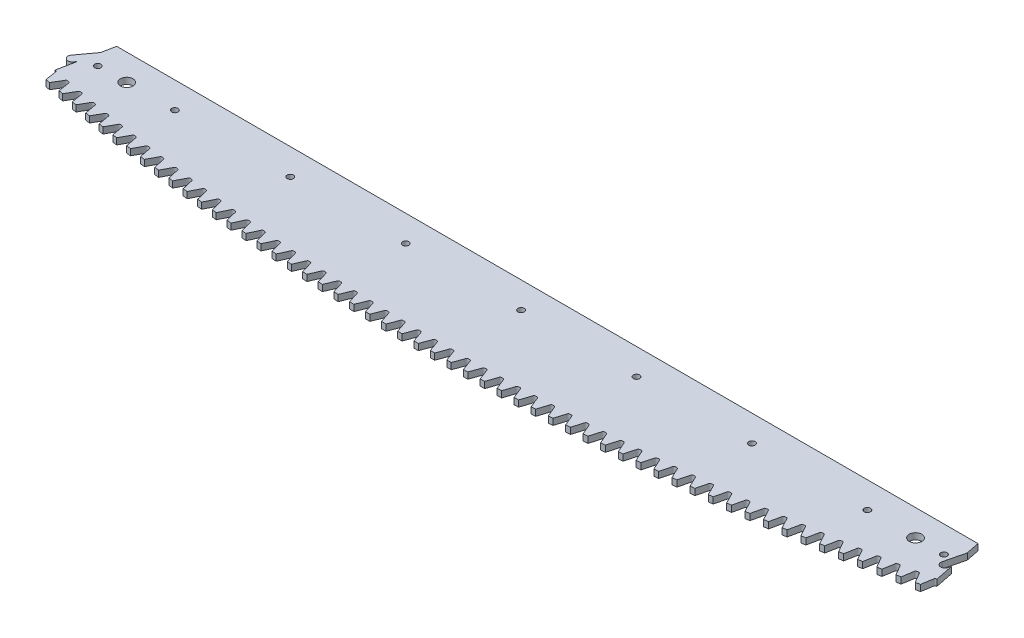
from build123d import *

# Parameters (mm, degrees)
SKETCH1_R                       = 6
SKETCH1_R_2                     = 3
BOSS_EXTRUDE1_DEPTH             = 6
CUT_EXTRUDE1_DEPTH              = 6
CIRPATTERN1_COUNT               = 28
CIRPATTERN1_ANGLE               = 11.25000009
CIRPATTERN1_THE_OTHER_WAY_COUNT = 28
CIRPATTERN1_THE_OTHER_WAY_ANGLE = 11.25000009
CUT_EXTRUDE2_DEPTH              = 6
BOSS_EXTRUDE4_DEPTH             = 6


with BuildPart() as part:
    # Sketch1 → Boss-Extrude1 (new body)
    with BuildSketch(Plane(origin=(0, 0, 0), x_dir=(1, 0, 0), z_dir=(0, 1, 0))):
        with BuildLine():
            Line((-410.440363801, -2063.423050098), (410.440363801, -2063.423050098))
            Line((410.440363801, -2063.423050098), (422.370547165, -2123.400132073))
            ThreePointArc((422.370547165, -2123.400132073), (0, -2165), (-422.370547165, -2123.400132073))
            Line((-422.370547165, -2123.400132073), (-410.440363801, -2063.423050098))
        make_face()
        with Locations((-375.934603339, -2088.423050098)):
            Circle(SKETCH1_R, mode=Mode.SUBTRACT)
        with Locations((375.934603339, -2088.423050098)):
            Circle(SKETCH1_R, mode=Mode.SUBTRACT)
        with Locations((0, -2088.423050098)):
            Circle(SKETCH1_R_2, mode=Mode.SUBTRACT)
        with Locations((110, -2088.423050098)):
            Circle(SKETCH1_R_2, mode=Mode.SUBTRACT)
        with Locations((220, -2088.423050098)):
            Circle(SKETCH1_R_2, mode=Mode.SUBTRACT)
        with Locations((330, -2088.423050098)):
            Circle(SKETCH1_R_2, mode=Mode.SUBTRACT)
        with Locations((-110, -2088.423050098)):
            Circle(SKETCH1_R_2, mode=Mode.SUBTRACT)
        with Locations((-220, -2088.423050098)):
            Circle(SKETCH1_R_2, mode=Mode.SUBTRACT)
        with Locations((-330, -2088.423050098)):
            Circle(SKETCH1_R_2, mode=Mode.SUBTRACT)
        with Locations((-403.219846097, -2088.633027037)):
            Circle(SKETCH1_R_2, mode=Mode.SUBTRACT)
        with Locations((403.219846097, -2088.633027037)):
            Circle(SKETCH1_R_2, mode=Mode.SUBTRACT)
    extrude(amount=BOSS_EXTRUDE1_DEPTH)

    # Sketch4 → Cut-Extrude1 (cut)
    with BuildSketch(Plane(origin=(0, 6, 0), x_dir=(1, 0, 0), z_dir=(0, 1, 0))):
        with BuildLine():
            ThreePointArc((5.775946522, -2164.992295238), (0, -2165), (-5.775946522, -2164.992295238))
            add(Edge.make_bspline(
                [(5.775946522, -2164.992295238), (5.674083922, -2164.720044005), (5.506178859, -2164.270486388), (5.272809935, -2163.64382032), (5.075526941, -2163.112827655), (4.879049735, -2162.582775587), (4.683376779, -2162.053665031), (4.488506537, -2161.525496899), (4.294437463, -2160.998272105), (4.101168048, -2160.471991549), (3.908696638, -2159.946656175), (3.71702211, -2159.42226675), (3.526141371, -2158.898824698), (3.336058649, -2158.376328989), (3.146750922, -2157.854787706), (2.958296557, -2157.334175032), (2.770396709, -2156.814591251), (2.584155873, -2156.29566751), (2.332577034, -2155.606535716), (2.139076064, -2155.010976967), (1.93879924, -2154.530288541), (1.81191477, -2154.337239961), (1.658884345, -2154.164884349), (1.480834065, -2154.018205562), (1.282601997, -2153.900243246), (1.06865708, -2153.814428877), (0.844082069, -2153.76051975), (0.485800933, -2153.741235255), (0, -2153.756378776), (-0.485800933, -2153.741235255), (-0.844082069, -2153.76051975), (-1.06865708, -2153.814428877), (-1.282601997, -2153.900243246), (-1.480834065, -2154.018205562), (-1.658884345, -2154.164884349), (-1.81191477, -2154.337239961), (-1.93879924, -2154.530288541), (-2.139076064, -2155.010976967), (-2.332577034, -2155.606535716), (-2.584155873, -2156.29566751), (-2.770396709, -2156.814591251), (-2.958296557, -2157.334175032), (-3.146750922, -2157.854787706), (-3.336058649, -2158.376328989), (-3.526141371, -2158.898824698), (-3.71702211, -2159.42226675), (-3.908696638, -2159.946656175), (-4.101168048, -2160.471991549), (-4.294437463, -2160.998272105), (-4.488506537, -2161.525496899), (-4.683376779, -2162.053665031), (-4.879049735, -2162.582775587), (-5.075526941, -2163.112827655), (-5.272809935, -2163.64382032), (-5.506178859, -2164.270486388), (-5.674083922, -2164.720044005), (-5.775946522, -2164.992295238)],
                knots=[0.009781048, 0.009781048, 0.009781048, 0.009781048, 0.041765812, 0.062584778, 0.083361118, 0.104094833, 0.124785921, 0.145434383, 0.166040219, 0.186603428, 0.207124012, 0.227601969, 0.2480373, 0.268430005, 0.288780084, 0.309087537, 0.329352363, 0.349574564, 0.369754138, 0.410064664, 0.418491096, 0.426917528, 0.43534396, 0.443770393, 0.452196825, 0.460623257, 0.46904969, 0.477476122, 0.5, 0.522523878, 0.53095031, 0.539376743, 0.547803175, 0.556229607, 0.56465604, 0.573082472, 0.581508904, 0.589935336, 0.630245862, 0.650425436, 0.670647637, 0.690912463, 0.711219916, 0.731569995, 0.7519627, 0.772398031, 0.792875988, 0.813396572, 0.833959781, 0.854565617, 0.875214079, 0.895905167, 0.916638882, 0.937415222, 0.958234188, 0.990218952, 0.990218952, 0.990218952, 0.990218952], degree=3))
        make_face()
    cut_extrude1 = extrude(amount=-CUT_EXTRUDE1_DEPTH, mode=Mode.SUBTRACT)

    # CirPattern1: Cut-Extrude1 ×28 about axis
    cirpattern1_axis = Axis((0, 6.3, 0), (0, -1, 0))
    for i in range(1, CIRPATTERN1_COUNT):
        add(cut_extrude1.rotate(cirpattern1_axis, i * CIRPATTERN1_ANGLE / (CIRPATTERN1_COUNT - 1)), mode=Mode.SUBTRACT)

    # CirPattern1 the other way: Cut-Extrude1 ×28 about axis
    cirpattern1_the_other_way_axis = Axis((0, 6.3, 0), (0, 1, 0))
    for i in range(1, CIRPATTERN1_THE_OTHER_WAY_COUNT):
        add(cut_extrude1.rotate(cirpattern1_the_other_way_axis, i * CIRPATTERN1_THE_OTHER_WAY_ANGLE / (CIRPATTERN1_THE_OTHER_WAY_COUNT - 1)), mode=Mode.SUBTRACT)

    # Sketch5 → Cut-Extrude2 (cut)
    with BuildSketch(Plane(origin=(0, 6, 0), x_dir=(1, 0, 0), z_dir=(0, 1, 0))):
        with BuildLine():
            Line((412.976537987, -2076.173258744), (408.22282014, -2095.60010014))
            ThreePointArc((408.22282014, -2095.60010014), (411.15744485, -2100.436211988), (415.993556699, -2097.501587278))
            Line((415.993556699, -2097.501587278), (416.669522218, -2094.739144209))
            Line((416.669522218, -2094.739144209), (412.976537987, -2076.173258744))
        make_face()
    extrude(amount=-CUT_EXTRUDE2_DEPTH, mode=Mode.SUBTRACT)

    # Sketch7 → Boss-Extrude4 (add)
    with BuildSketch(Plane(origin=(0, 6, 0), x_dir=(1, 0, 0), z_dir=(0, 1, 0))):
        with BuildLine():
            Line((-412.976537987, -2076.173258744), (-424.802730954, -2092.302150829))
            ThreePointArc((-424.802730954, -2092.302150829), (-423.942191131, -2097.893167839), (-418.35117412, -2097.032628016))
            Line((-418.35117412, -2097.032628016), (-416.669522218, -2094.739144209))
            Line((-416.669522218, -2094.739144209), (-412.976537987, -2076.173258744))
        make_face()
    extrude(amount=-BOSS_EXTRUDE4_DEPTH)


solid = part.part
